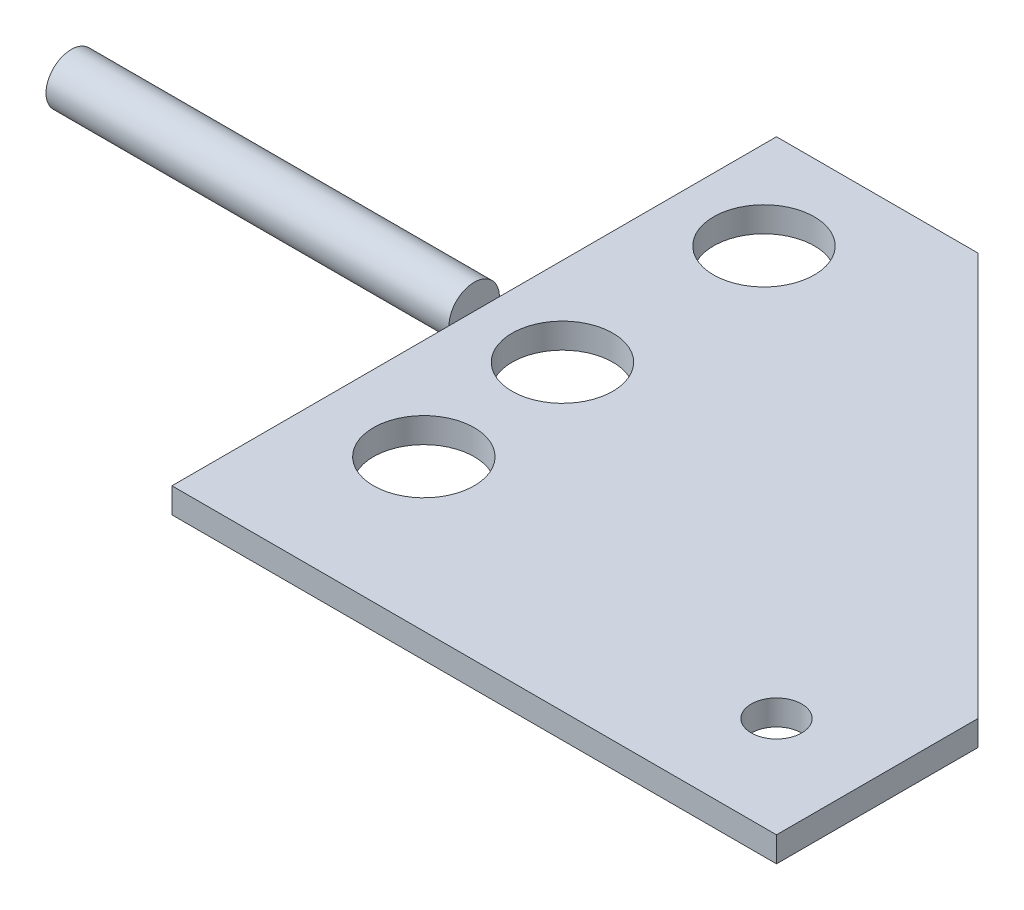
from build123d import *

# Parameters (mm, degrees)
BOSS_EXTRUDE1_DEPTH     = 6.35
SKETCH2_R               = 6.35
BOSS_EXTRUDE2_DEPTH     = 101.6
SKETCH3_R               = 12.7
SKETCH3_R_2             = 6.35
CUT_EXTRUDE1_DEPTH      = 101.6
SKETCH4_R               = 12.7
CUT_EXTRUDE2_DEPTH      = 7.35
SKETCH5_R               = 12.7
CUT_EXTRUDE3_DEPTH      = 7.35
CUT_EXTRUDE3_DEPTH_BACK = 7.35


with BuildPart() as part:
    # Sketch1 → Boss-Extrude1 (new body)
    with BuildSketch(Plane(origin=(0, 0, 0), x_dir=(1, 0, 0), z_dir=(0, 1, 0))):
        Polygon((-76.2, 76.2), (-76.2, -76.2), (76.2, -76.2), (76.2, -25.4), (-25.4, 76.2), align=None)
    extrude(amount=BOSS_EXTRUDE1_DEPTH)

    # Sketch2 → Boss-Extrude2 (add)
    with BuildSketch(Plane.ZY.offset(76.2)):
        with Locations((0, 6.35)):
            Circle(SKETCH2_R)
    extrude(amount=BOSS_EXTRUDE2_DEPTH)

    # Sketch3 → Cut-Extrude1 (cut)
    with BuildSketch(Plane(origin=(0, 6.35, 0), x_dir=(1, 0, 0), z_dir=(0, 1, 0))):
        with Locations((-50.8, -38.1)):
            Circle(SKETCH3_R)
        with Locations((50.8, -50.8)):
            Circle(SKETCH3_R_2)
    extrude(amount=-CUT_EXTRUDE1_DEPTH, mode=Mode.SUBTRACT)

    # Sketch4 → Cut-Extrude2 (cut, through all)
    with BuildSketch(Plane(origin=(0, 6.35, 0), x_dir=(1, 0, 0), z_dir=(0, 1, 0))):
        with Locations((-53.956209782, 0)):
            Circle(SKETCH4_R)
    extrude(amount=-CUT_EXTRUDE2_DEPTH, mode=Mode.SUBTRACT)

    # Sketch5 → Cut-Extrude3 (cut, two sides)
    with BuildSketch(Plane(origin=(0, 6.35, 0), x_dir=(1, 0, 0), z_dir=(0, 1, 0))) as cut_extrude3_sk:
        with Locations((-53.956209782, 50.8)):
            Circle(SKETCH5_R)
    extrude(amount=CUT_EXTRUDE3_DEPTH, mode=Mode.SUBTRACT)
    extrude(cut_extrude3_sk.sketch, amount=-CUT_EXTRUDE3_DEPTH_BACK, mode=Mode.SUBTRACT)


solid = part.part
